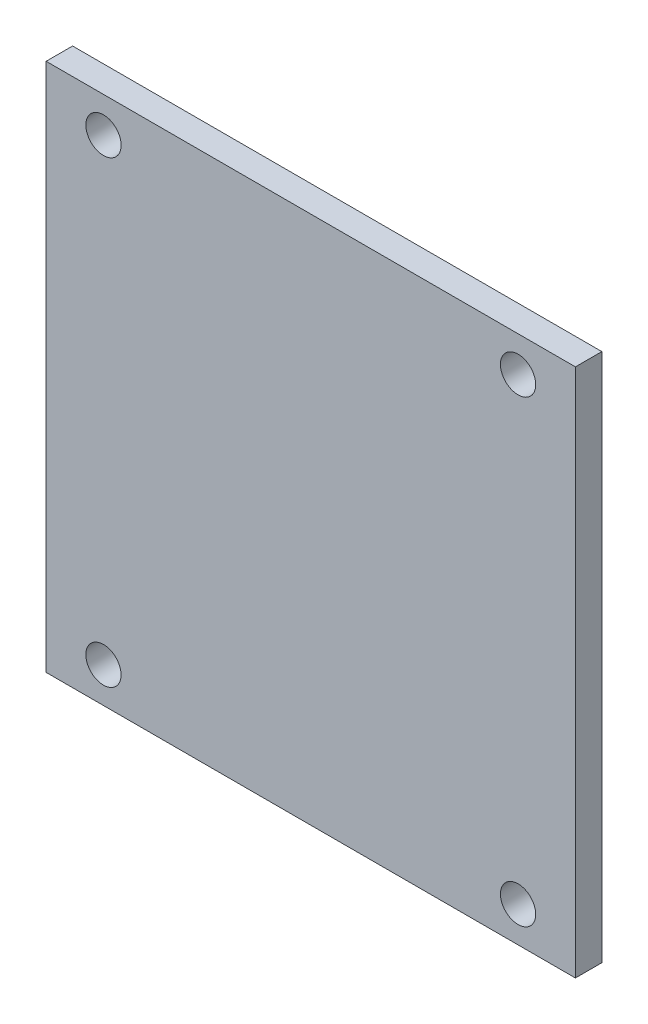
from build123d import *

# Parameters (mm, degrees)
SKETCH1_W           = 60
SKETCH1_H           = 60
BOSS_EXTRUDE1_DEPTH = 3
SKETCH2_R           = 2
CUT_EXTRUDE1_DEPTH  = 4


with BuildPart() as part:
    # Sketch1 → Boss-Extrude1 (new body)
    with BuildSketch(Plane.XY):
        Rectangle(SKETCH1_W, SKETCH1_H)
    extrude(amount=BOSS_EXTRUDE1_DEPTH)

    # Sketch2 → Cut-Extrude1 (cut, through all)
    with BuildSketch(Plane.XY):
        with Locations((23.5, 26)):
            Circle(SKETCH2_R)
        with Locations((-23.5, 26)):
            Circle(SKETCH2_R)
        with Locations((-23.5, -26)):
            Circle(SKETCH2_R)
        with Locations((23.5, -26)):
            Circle(SKETCH2_R)
    extrude(amount=CUT_EXTRUDE1_DEPTH, mode=Mode.SUBTRACT)


solid = part.part
